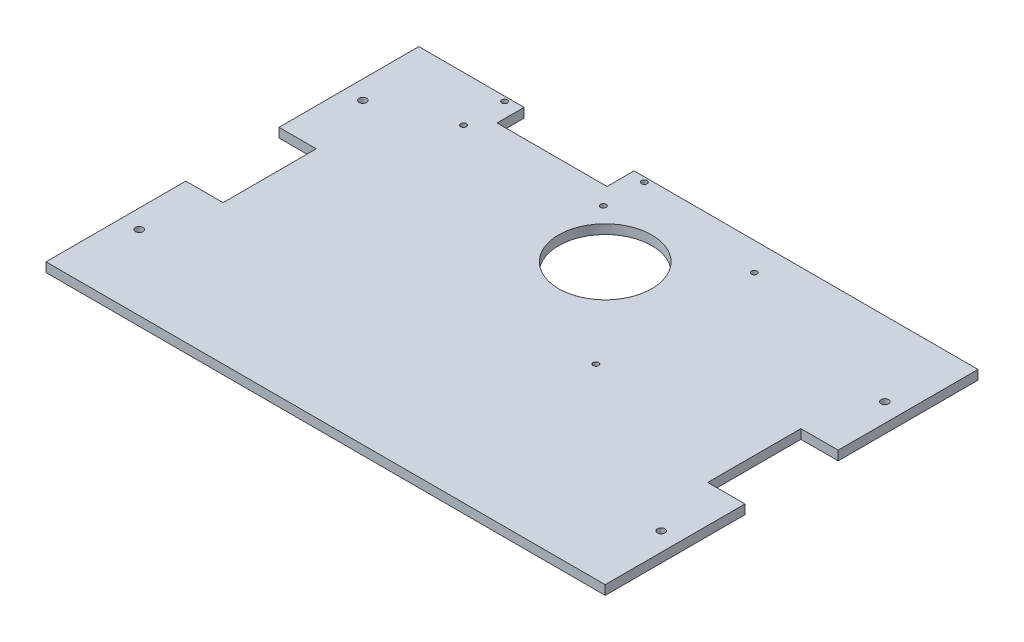
from build123d import *

# Parameters (mm, degrees)
SKETCH1_W           = 300
SKETCH1_H           = 200
BOSS_EXTRUDE1_DEPTH = 5
SKETCH2_R           = 2
SKETCH2_R_2         = 25
CUT_EXTRUDE2_DEPTH  = 6
SKETCH4_R           = 1.5
CUT_EXTRUDE3_DEPTH  = 6
SKETCH6_W           = 59
SKETCH6_H           = 14.5
CUT_EXTRUDE4_DEPTH  = 5
SKETCH8_R           = 1.5
CUT_EXTRUDE6_DEPTH  = 6
SKETCH9_W           = 20
SKETCH9_H           = 50
CUT_EXTRUDE7_DEPTH  = 6


with BuildPart() as part:
    # Sketch1 → Boss-Extrude1 (new body)
    with BuildSketch(Plane(origin=(0, 0, 0), x_dir=(1, 0, 0), z_dir=(0, 1, 0))):
        Rectangle(SKETCH1_W, SKETCH1_H)
    extrude(amount=BOSS_EXTRUDE1_DEPTH)

    # Sketch2 → Cut-Extrude2 (cut, through all)
    with BuildSketch(Plane(origin=(0, 5, 0), x_dir=(1, 0, 0), z_dir=(0, 1, 0))):
        with Locations((-140, 0)):
            Circle(SKETCH2_R)
        with Locations((-140, 60)):
            Circle(SKETCH2_R)
        with Locations((-140, -60)):
            Circle(SKETCH2_R)
        with Locations((140, -60)):
            Circle(SKETCH2_R)
        with Locations((140, 60)):
            Circle(SKETCH2_R)
        with Locations((140, 0)):
            Circle(SKETCH2_R)
        with Locations((0, 50)):
            Circle(SKETCH2_R_2)
    extrude(amount=-CUT_EXTRUDE2_DEPTH, mode=Mode.SUBTRACT)

    # Sketch4 → Cut-Extrude3 (cut, through all)
    with BuildSketch(Plane(origin=(0, 5, 0), x_dir=(1, 0, 0), z_dir=(0, 1, 0))):
        with Locations((-101.5, 97.5)):
            Circle(SKETCH4_R)
        with Locations((-26.5, 97.5)):
            Circle(SKETCH4_R)
        with Locations((-26.5, 75.5)):
            Circle(SKETCH4_R)
        with Locations((-101.5, 75.5)):
            Circle(SKETCH4_R)
    extrude(amount=-CUT_EXTRUDE3_DEPTH, mode=Mode.SUBTRACT)

    # Sketch6 → Cut-Extrude4 (cut)
    with BuildSketch(Plane.XZ):
        with Locations((-64, -92.75)):
            Rectangle(SKETCH6_W, SKETCH6_H)
    extrude(amount=-CUT_EXTRUDE4_DEPTH, mode=Mode.SUBTRACT)

    # Sketch8 → Cut-Extrude6 (cut, through all)
    with BuildSketch(Plane(origin=(0, 5, 0), x_dir=(1, 0, 0), z_dir=(0, 1, 0))):
        with Locations((45, 85)):
            Circle(SKETCH8_R)
        with Locations((45, 0)):
            Circle(SKETCH8_R)
    extrude(amount=-CUT_EXTRUDE6_DEPTH, mode=Mode.SUBTRACT)

    # Sketch9 → Cut-Extrude7 (cut, through all)
    with BuildSketch(Plane(origin=(0, 5, 0), x_dir=(1, 0, 0), z_dir=(0, 1, 0))):
        with Locations((-140, 0)):
            Rectangle(SKETCH9_W, SKETCH9_H)
        with Locations((140, 0)):
            Rectangle(SKETCH9_W, SKETCH9_H)
    extrude(amount=-CUT_EXTRUDE7_DEPTH, mode=Mode.SUBTRACT)


solid = part.part
